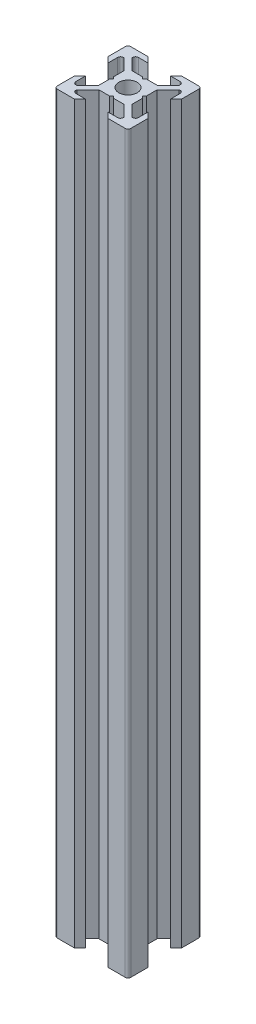
from build123d import *

# Parameters (mm, degrees)
ESQUISSE1_R      = 2.5
EXTRUSION1_DEPTH = 200
CONG_1_R         = 0.75


with BuildPart() as part:
    # Esquisse1 → Extrusion1 (new body)
    with BuildSketch(Plane(origin=(0, 0, 0), x_dir=(1, 0, 0), z_dir=(0, 1, 0))):
        Polygon((0, 4), (-0.5, 4.5), (-3.439339828, 4.5), (-6.439339828, 7.5), (-6.439339828, 8.5), (-3, 8.5), (-4.5, 10), (-10, 10), (-10, 4.5), (-8.5, 3), (-8.5, 6.439339828), (-7.5, 6.439339828), (-4.5, 3.439339828), (-4.5, 0.5), (-4, 0), (-4.5, -0.5), (-4.5, -3.439339828), (-7.5, -6.439339828), (-8.5, -6.439339828), (-8.5, -3), (-10, -4.5), (-10, -10), (-4.5, -10), (-3, -8.5), (-6.439339828, -8.5), (-6.439339828, -7.5), (-3.439339828, -4.5), (-0.5, -4.5), (0, -4), (0.5, -4.5), (3.439339828, -4.5), (6.439339828, -7.5), (6.439339828, -8.5), (3, -8.5), (4.5, -10), (10, -10), (10, -4.5), (8.5, -3), (8.5, -6.439339828), (7.5, -6.439339828), (4.5, -3.439339828), (4.5, -0.5), (4, 0), (4.5, 0.5), (4.5, 3.439339828), (7.5, 6.439339828), (8.5, 6.439339828), (8.5, 3), (10, 4.5), (10, 10), (4.5, 10), (3, 8.5), (6.439339828, 8.5), (6.439339828, 7.5), (3.439339828, 4.5), (0.5, 4.5), align=None)
        Circle(ESQUISSE1_R, mode=Mode.SUBTRACT)
    extrude(amount=EXTRUSION1_DEPTH)

    # Congé1
    cong_1_edges = [part.edges().sort_by_distance(p)[0] for p in [
        (6.439339828, 100, -8.5),
        (10, 100, -10),
        (8.5, 100, -6.439339828),
        (8.5, 100, 6.439339828),
        (10, 100, 10),
        (6.439339828, 100, 8.5),
        (-6.439339828, 100, 8.5),
        (-10, 100, 10),
        (-8.5, 100, 6.439339828),
        (-8.5, 100, -6.439339828),
        (-10, 100, -10),
        (-6.439339828, 100, -8.5),
    ]]
    fillet(cong_1_edges, radius=CONG_1_R)


solid = part.part
